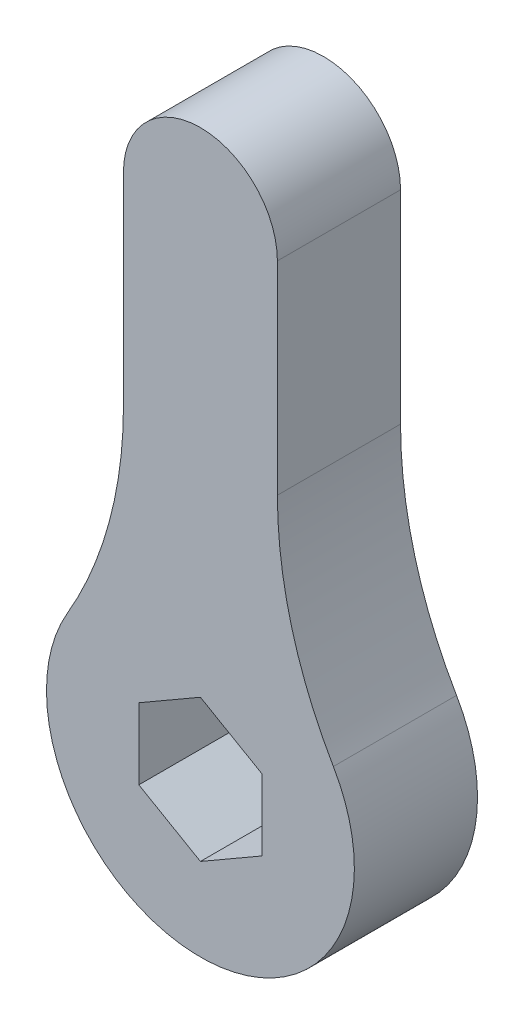
from build123d import *

# Parameters (mm, degrees)
BOSS_EXTRUDE1_DEPTH = 6


with BuildPart() as part:
    # Sketch1 → Boss-Extrude1 (new body)
    with BuildSketch(Plane.XY):
        with BuildLine():
            Line((-3.75, 13.863170633), (-3.75, 23.75))
            ThreePointArc((-3.75, 23.75), (0, 27.5), (3.75, 23.75))
            Line((3.75, 23.75), (3.75, 13.863170633))
            ThreePointArc((3.75, 13.863170633), (4.443854017, 8.640840954), (6.477272727, 3.780864718))
            ThreePointArc((6.477272727, 3.780864718), (0, -7.5), (-6.477272727, 3.780864718))
            ThreePointArc((-6.477272727, 3.780864718), (-4.443854017, 8.640840954), (-3.75, 13.863170633))
        make_face()
        Polygon((0, 3.464101615), (-3, 1.732050808), (-3, -1.732050808), (0, -3.464101615), (3, -1.732050808), (3, 1.732050808), align=None, mode=Mode.SUBTRACT)
    extrude(amount=BOSS_EXTRUDE1_DEPTH)


solid = part.part
